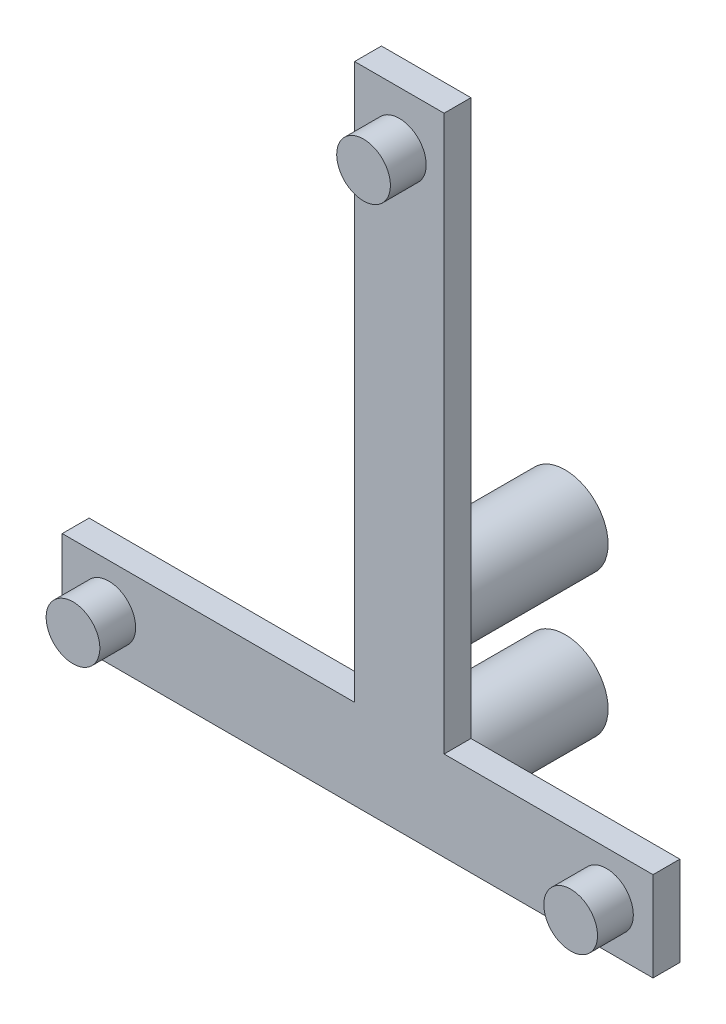
from build123d import *

# Parameters (mm, degrees)
BOSS_EXTRUDE2_DEPTH = 1.5
SKETCH5_R           = 1.5
BOSS_EXTRUDE5_DEPTH = 3.5
SKETCH6_R           = 2.4
BOSS_EXTRUDE6_DEPTH = 7.76


with BuildPart() as part:
    # Sketch4 → Boss-Extrude2 (new body)
    with BuildSketch(Plane.XY):
        Polygon((-139.561248012, 16.070535031), (-106.561248012, 16.070535031), (-106.561248012, 21.070535031), (-118.231248012, 21.070535031), (-118.231248012, 52.070535031), (-123.231248012, 52.070535031), (-123.231248012, 21.070535031), (-139.561248012, 21.070535031), align=None)
    extrude(amount=BOSS_EXTRUDE2_DEPTH)

    # Sketch5 → Boss-Extrude5 (add)
    with BuildSketch(Plane(origin=(0, 0, 0), x_dir=(-1, 0, 0), z_dir=(0, 0, -1))):
        with Locations((136.961248012, 18.570535031)):
            Circle(SKETCH5_R)
        with Locations((109.161248012, 18.570535031)):
            Circle(SKETCH5_R)
        with Locations((120.731248012, 49.070535031)):
            Circle(SKETCH5_R)
    extrude(amount=-BOSS_EXTRUDE5_DEPTH)

    # Sketch6 → Boss-Extrude6 (add)
    with BuildSketch(Plane(origin=(0, 0, 0), x_dir=(-1, 0, 0), z_dir=(0, 0, -1))):
        with Locations((120.731248012, 18.570535031)):
            Circle(SKETCH6_R)
        with Locations((120.731248012, 26.540535031)):
            Circle(SKETCH6_R)
    extrude(amount=BOSS_EXTRUDE6_DEPTH)


solid = part.part
